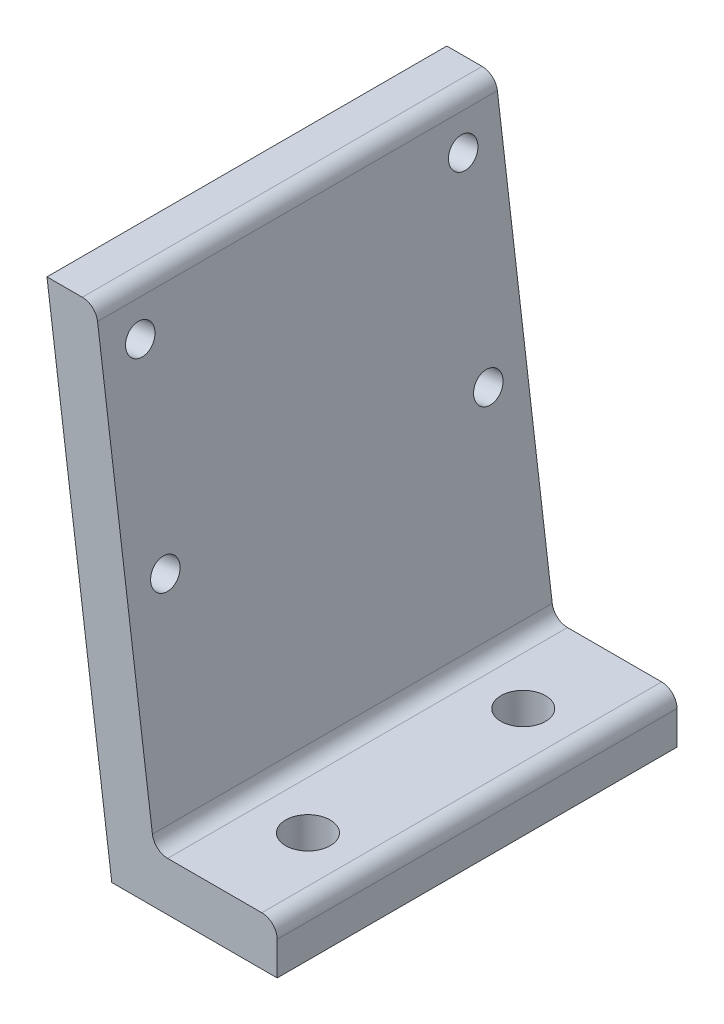
from build123d import *

# Parameters (mm, degrees)
BOSS_EXTRUDE1_DEPTH = 26
CUT_EXTRUDE1_START  = -3.147838
SKETCH2_R           = 0.95
CUT_EXTRUDE1_DEPTH  = 3.147838
SKETCH3_R           = 1.45
CUT_EXTRUDE2_DEPTH  = 3.175
FILLET1_R           = 1
FILLET2_R           = 1
FILLET3_R           = 1


with BuildPart() as part:
    # Sketch1 → Boss-Extrude1 (new body)
    with BuildSketch(Plane.XY):
        Polygon((0, 0), (8, 0), (8, -3.175), (-2.75700332, -3.175), (-6.969883243, 28.825), (-3.794883243, 28.825), align=None)
    extrude(amount=BOSS_EXTRUDE1_DEPTH)

    # Sketch2 → Cut-Extrude1 (cut)
    with BuildSketch(Plane(origin=(0, 0, 0), x_dir=(0, 0, -1), z_dir=(0.991444861, 0.130526192, 0)).offset(CUT_EXTRUDE1_START)):
        with Locations((-23.5, 26.073729789)):
            Circle(SKETCH2_R)
        with Locations((-2.5, 26.073729789)):
            Circle(SKETCH2_R)
        with Locations((-2.5, 13.573729789)):
            Circle(SKETCH2_R)
        with Locations((-23.5, 13.573729789)):
            Circle(SKETCH2_R)
    extrude(amount=CUT_EXTRUDE1_DEPTH, mode=Mode.SUBTRACT)

    # Sketch3 → Cut-Extrude2 (cut)
    with BuildSketch(Plane(origin=(0, 0, 0), x_dir=(1, 0, 0), z_dir=(0, 1, 0))):
        with Locations((4, -20)):
            Circle(SKETCH3_R)
        with Locations((4, -6)):
            Circle(SKETCH3_R)
    extrude(amount=-CUT_EXTRUDE2_DEPTH, mode=Mode.SUBTRACT)

    # Fillet1
    fillet1_edges = [part.edges().sort_by_distance(p)[0] for p in [
        (-3.794883243, 28.825, 13),
    ]]
    fillet(fillet1_edges, radius=FILLET1_R)

    # Fillet2
    fillet2_edges = [part.edges().sort_by_distance(p)[0] for p in [
        (0, 0, 13),
    ]]
    fillet(fillet2_edges, radius=FILLET2_R)

    # Fillet3
    fillet3_edges = [part.edges().sort_by_distance(p)[0] for p in [
        (8, 0, 13),
    ]]
    fillet(fillet3_edges, radius=FILLET3_R)


solid = part.part
